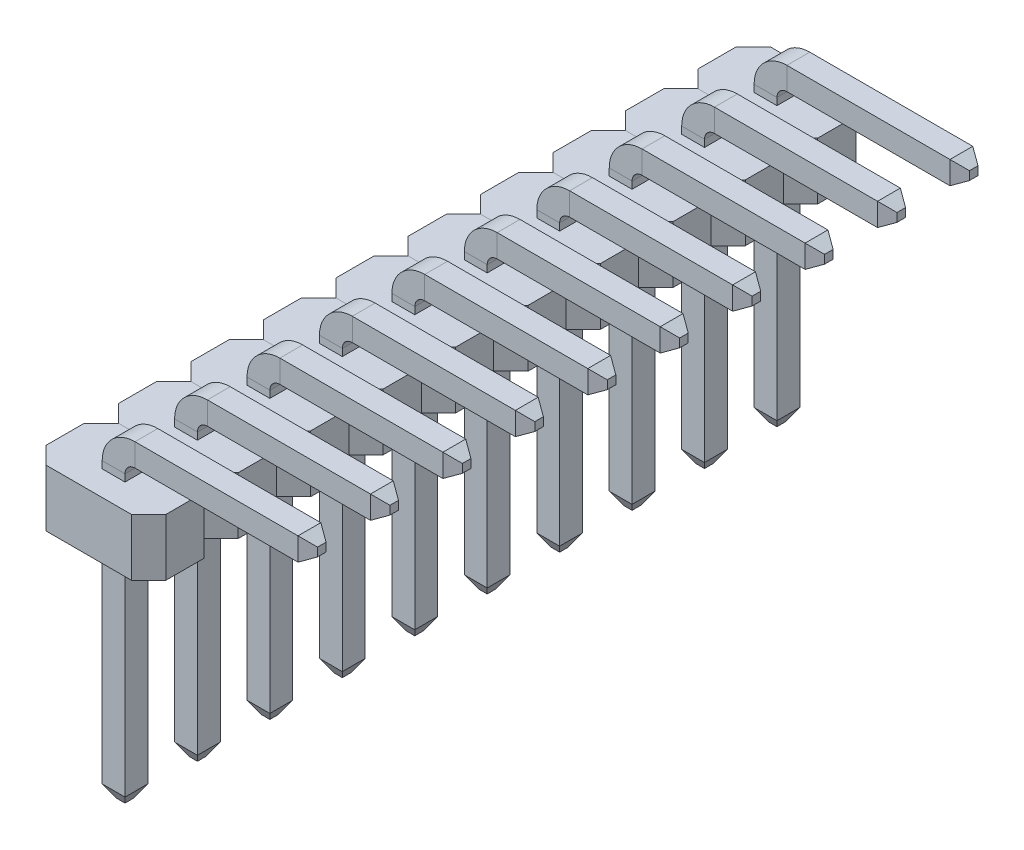
from build123d import *

# Parameters (mm, degrees)
SKETCH2_W           = 0.4
SKETCH2_H           = 0.4
CHAMFER1_SIZE       = 0.125
CHAMFER1_SIZE2      = 0.216506351
CHAMFER2_SIZE       = 0.125
CHAMFER2_SIZE2      = 0.216506351
BOSS_EXTRUDE1_DEPTH = 1
LPATTERN1_COUNT     = 10
LPATTERN1_PITCH     = 1.27


with BuildPart() as part:
    # Sweep1: sweep along a path in Sketch1
    with BuildLine(Plane.XY) as sweep1_path:
        Line((3.45, 0), (0.375, 0))
        ThreePointArc((0.375, 0), (0.109834957, -0.109834957), (0, -0.375))
        Line((0, -0.375), (0, -5.5))
    # Sketch2 → Sweep1 (sweep)
    with BuildSketch(Plane(origin=(0, -5.5, 0), x_dir=(1, 0, 0), z_dir=(0, 1, 0))):
        Rectangle(SKETCH2_W, SKETCH2_H)
    sweep(path=sweep1_path.line)

    # Chamfer1
    chamfer1_edges = [part.edges().sort_by_distance(p)[0] for p in [
        (-0.2, -5.5, 0),
        (0, -5.5, 0.2),
        (0.2, -5.5, 0),
        (0, -5.5, -0.2),
    ]]
    chamfer1_side = [part.faces().sort_by_distance(p)[0] for p in [
        (0, -5.5, 0),
    ]]
    chamfer(chamfer1_edges, length=CHAMFER1_SIZE, length2=CHAMFER1_SIZE2, reference=chamfer1_side[0])

    # Chamfer2
    chamfer2_edges = [part.edges().sort_by_distance(p)[0] for p in [
        (3.45, 0, 0.2),
        (3.45, -0.2, 0),
        (3.45, 0, -0.2),
        (3.45, 0.2, 0),
    ]]
    chamfer2_side = [part.faces().sort_by_distance(p)[0] for p in [
        (3.45, 0, 0),
    ]]
    chamfer(chamfer2_edges, length=CHAMFER2_SIZE, length2=CHAMFER2_SIZE2, reference=chamfer2_side[0])

    # Sketch3 → Boss-Extrude1 (add)
    with BuildSketch(Plane(origin=(0, -1.5, 0), x_dir=(1, 0, 0), z_dir=(0, 1, 0))):
        Polygon((-0.75, 0.635), (-1.05, 0.335), (-1.05, -0.335), (-0.75, -0.635), (0.75, -0.635), (1.05, -0.335), (1.05, 0.335), (0.75, 0.635), align=None)
    extrude(amount=BOSS_EXTRUDE1_DEPTH)


with BuildPart() as lpattern1_1:
    # LPattern1: pattern copy
    add(part.part.moved(Location(Vector(0, 0, 1) * (1 * LPATTERN1_PITCH))))


with BuildPart() as lpattern1_2:
    # LPattern1: pattern copy
    add(part.part.moved(Location(Vector(0, 0, 1) * (2 * LPATTERN1_PITCH))))


with BuildPart() as lpattern1_3:
    # LPattern1: pattern copy
    add(part.part.moved(Location(Vector(0, 0, 1) * (3 * LPATTERN1_PITCH))))


with BuildPart() as lpattern1_4:
    # LPattern1: pattern copy
    add(part.part.moved(Location(Vector(0, 0, 1) * (4 * LPATTERN1_PITCH))))


with BuildPart() as lpattern1_5:
    # LPattern1: pattern copy
    add(part.part.moved(Location(Vector(0, 0, 1) * (5 * LPATTERN1_PITCH))))


with BuildPart() as lpattern1_6:
    # LPattern1: pattern copy
    add(part.part.moved(Location(Vector(0, 0, 1) * (6 * LPATTERN1_PITCH))))


with BuildPart() as lpattern1_7:
    # LPattern1: pattern copy
    add(part.part.moved(Location(Vector(0, 0, 1) * (7 * LPATTERN1_PITCH))))


with BuildPart() as lpattern1_8:
    # LPattern1: pattern copy
    add(part.part.moved(Location(Vector(0, 0, 1) * (8 * LPATTERN1_PITCH))))


with BuildPart() as lpattern1_9:
    # LPattern1: pattern copy
    add(part.part.moved(Location(Vector(0, 0, 1) * (9 * LPATTERN1_PITCH))))


solid = Compound([part.part, lpattern1_1.part, lpattern1_2.part, lpattern1_3.part, lpattern1_4.part, lpattern1_5.part, lpattern1_6.part, lpattern1_7.part, lpattern1_8.part, lpattern1_9.part])
